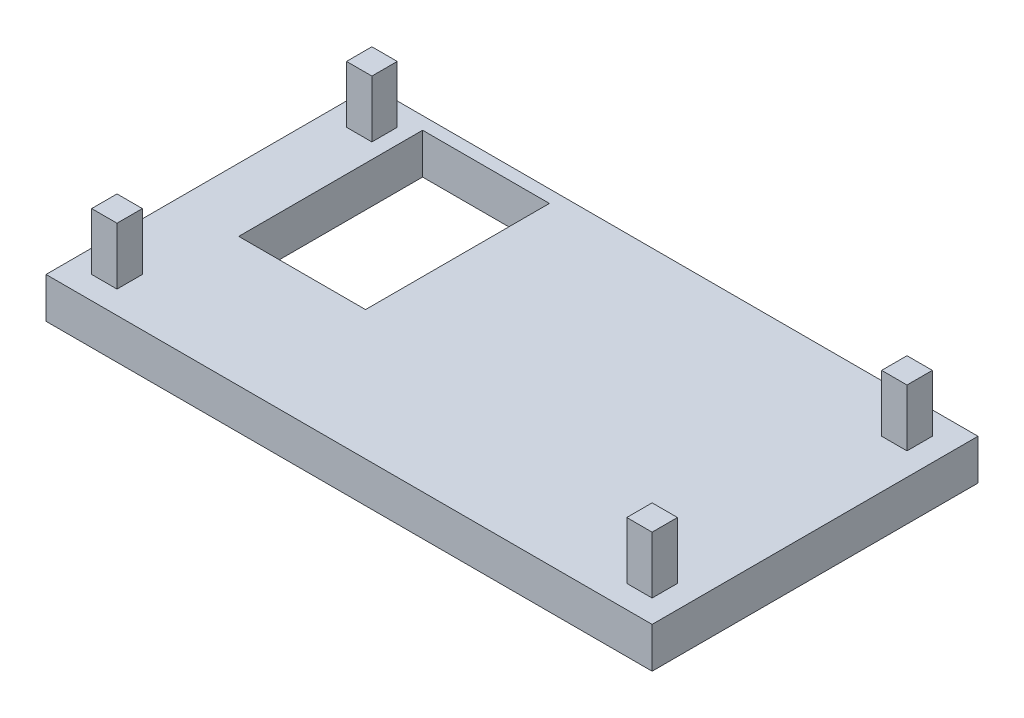
from build123d import *

# Parameters (mm, degrees)
SCHIZZO1_W                   = 47.8
SCHIZZO1_H                   = 25.7
ESTRUSIONE_ESTRUSIONE2_DEPTH = 3.2
SCHIZZO3_W                   = 2
SCHIZZO3_H                   = 2
ESTRUSIONE_ESTRUSIONE4_DEPTH = 4.5
SCHIZZO4_W                   = 10
SCHIZZO4_H                   = 14.5
TAGLIO_ESTRUSIONE1_DEPTH     = 5


with BuildPart() as part:
    # Schizzo1 → Estrusione-Estrusione2 (new body)
    with BuildSketch(Plane(origin=(0, 0, 0), x_dir=(1, 0, 0), z_dir=(0, 1, 0))):
        Rectangle(SCHIZZO1_W, SCHIZZO1_H)
    extrude(amount=ESTRUSIONE_ESTRUSIONE2_DEPTH)

    # Schizzo3 → Estrusione-Estrusione4 (add)
    with BuildSketch(Plane(origin=(0, 3.2, 0), x_dir=(1, 0, 0), z_dir=(0, 1, 0))):
        with Locations((21.1, -10.05)):
            Rectangle(SCHIZZO3_W, SCHIZZO3_H)
        with Locations((21.1, 10.05)):
            Rectangle(SCHIZZO3_W, SCHIZZO3_H)
        with Locations((-21.1, 10.05)):
            Rectangle(SCHIZZO3_W, SCHIZZO3_H)
        with Locations((-21.1, -10.05)):
            Rectangle(SCHIZZO3_W, SCHIZZO3_H)
    extrude(amount=ESTRUSIONE_ESTRUSIONE4_DEPTH)

    # Schizzo4 → Taglio-Estrusione1 (cut)
    with BuildSketch(Plane.XZ):
        with Locations((-13.9, -4.6)):
            Rectangle(SCHIZZO4_W, SCHIZZO4_H)
    extrude(amount=-TAGLIO_ESTRUSIONE1_DEPTH, mode=Mode.SUBTRACT)


solid = part.part
